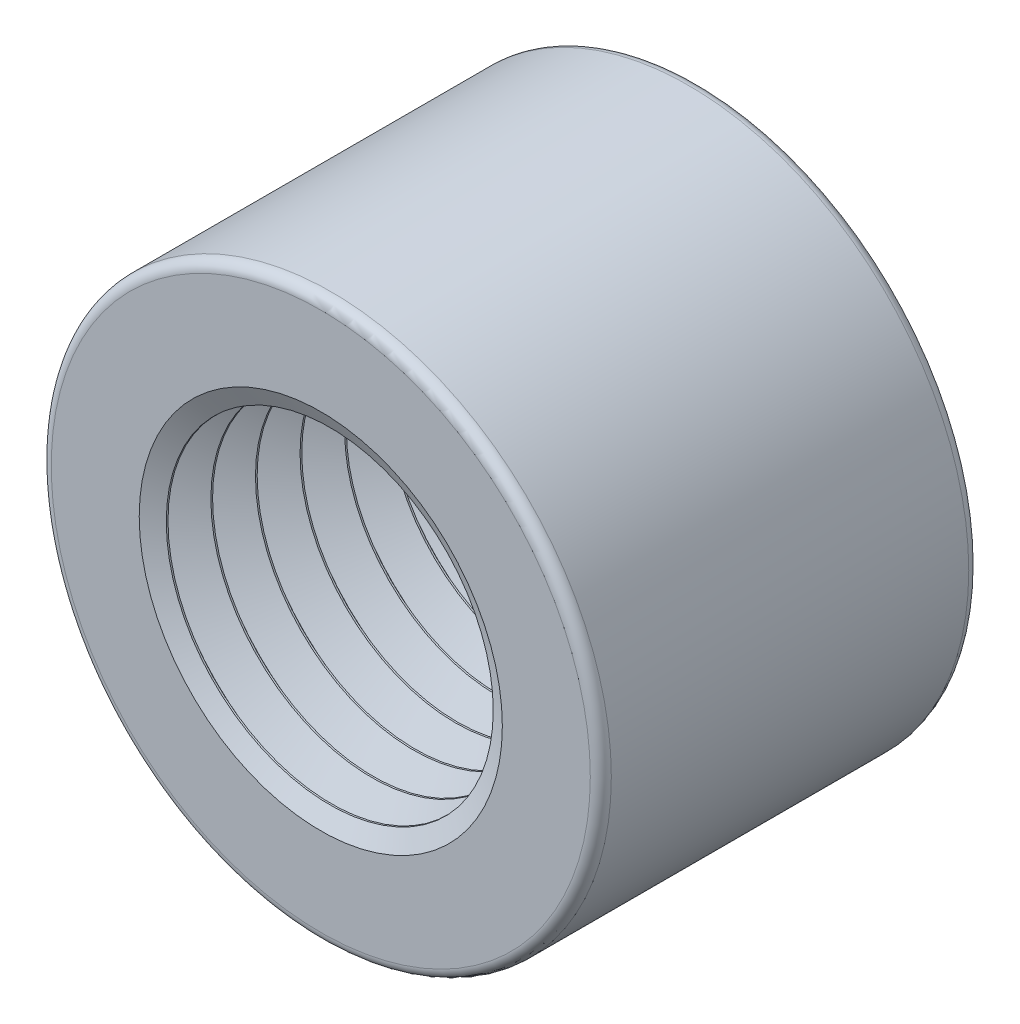
from build123d import *

# Parameters (mm, degrees)
SKETCH1_R      = 9.398
EXTRUDE1_DEPTH = 6.35
SKETCH5_W      = 12.7
SKETCH5_H      = 4.869399387
FILLET1_R      = 0.352777778


with BuildPart() as part:
    # Sketch1 → Extrude1 (new body, symmetric)
    with BuildSketch(Plane.XY):
        Circle(SKETCH1_R)
    extrude(amount=EXTRUDE1_DEPTH, both=True)

    # Sketch5 → Cut-Revolve7 (revolve, cut)
    with BuildSketch(Plane(origin=(0, 0, 0), x_dir=(0, 0, -1), z_dir=(1, 0, 0))):
        with Locations((0, 2.434699694)):
            Rectangle(SKETCH5_W, SKETCH5_H)
    revolve(axis=Axis((0, 0, 0), (0, 0, -1)), mode=Mode.SUBTRACT)

    # Fillet1
    fillet1_edges = [part.edges().sort_by_distance(p)[0] for p in [
        (-9.398, 0, -6.35),
        (-9.398, 0, 6.35),
    ]]
    fillet(fillet1_edges, radius=FILLET1_R)

    # Sketch2 → Cut-Revolve5 (revolve, cut)
    with BuildSketch(Plane(origin=(0, 0, 0), x_dir=(0, 0, -1), z_dir=(1, 0, 0))):
        Polygon((-22.120436281, 7.622813225), (-21.540434076, 6.455429709), (-21.486747793, 6.452070868), (-20.765765115, 7.53805927), (-20.712078832, 7.534700429), (-20.132076627, 6.367316913), (-20.078390344, 6.363958072), (-19.357407666, 7.449946474), (-19.303721383, 7.446587633), (-18.723719178, 6.279204117), (-18.670032896, 6.275845277), (-17.949050217, 7.361833678), (-17.895363935, 7.358474838), (-17.31536173, 6.191091322), (-17.261675447, 6.187732481), (-16.540692769, 7.273720883), (-16.487006486, 7.270362042), (-15.907004281, 6.102978526), (-15.853317998, 6.099619685), (-15.13233532, 7.185608087), (-15.078649037, 7.182249246), (-14.498646832, 6.01486573), (-14.44496055, 6.01150689), (-13.723977871, 7.097495291), (-13.670291589, 7.094136451), (-13.090289384, 5.926752935), (-13.036603101, 5.923394094), (-12.315620423, 7.009382496), (-12.26193414, 7.006023655), (-11.681931935, 5.838640139), (-11.628245652, 5.835281298), (-10.907262974, 6.9212697), (-10.853576692, 6.917910859), (-10.273574486, 5.750527343), (-10.219888204, 5.747168503), (-9.498905526, 6.833156904), (-9.445219243, 6.829798064), (-8.865217038, 5.662414548), (-8.811530755, 5.659055707), (-8.090548077, 6.745044109), (-8.036861794, 6.741685268), (-7.456859589, 5.574301752), (-7.403173306, 5.570942911), (-6.682190628, 6.656931313), (-6.628504346, 6.653572472), (-6.04850214, 5.486188956), (-5.994815858, 5.482830116), (-5.27383318, 6.568818517), (-5.220146897, 6.565459677), (-4.640144692, 5.398076161), (-4.586458409, 5.39471732), (-3.865475731, 6.480705722), (-3.811789448, 6.477346881), (-3.231787243, 5.309963365), (-3.178100961, 5.306604524), (-2.457118282, 6.392592926), (-2.403432, 6.389234085), (-1.823429795, 5.221850569), (-1.769743512, 5.218491729), (-1.048760834, 6.30448013), (-0.995074551, 6.30112129), (-0.415072346, 5.133737774), (-0.361386063, 5.130378933), (0.359596615, 6.216367335), (0.413282898, 6.213008494), (0.993285103, 5.045624978), (1.046971385, 5.042266137), (1.767954064, 6.128254539), (1.821640346, 6.124895698), (2.401642551, 4.957512182), (2.455328834, 4.954153342), (3.176311512, 6.040141743), (3.229997795, 6.036782903), (3.81, 4.869399387), (3.81, 0), (-23.582480012, 0), (-23.582480012, 7.714284861), (-23.528793729, 7.71092602), (-22.948791524, 6.543542504), (-22.895105242, 6.540183664), (-22.174122563, 7.626172065), align=None)
    revolve(axis=Axis((0, 0, -97.9740637), (0, 0, 1)), mode=Mode.SUBTRACT)


solid = part.part
